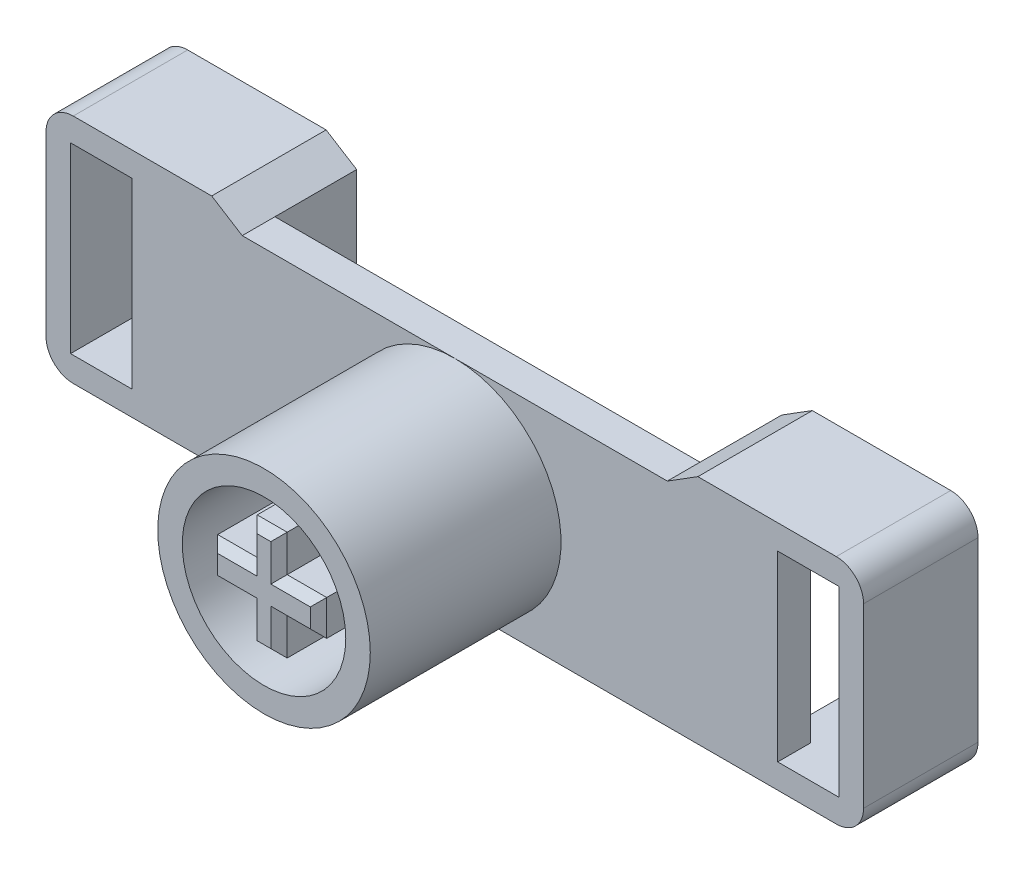
from build123d import *

# Parameters (mm, degrees)
SKETCH1_R               = 3.9
SKETCH1_R_2             = 3
SKETCH1_W               = 1.45
SKETCH1_H               = 1.3
SKETCH1_W_2             = 1.1
SKETCH1_H_2             = 1.35
BOSS_EXTRUDE1_DEPTH     = 7
SKETCH2_R               = 3
BOSS_EXTRUDE2_DEPTH     = 3
SKETCH4_W               = 30
SKETCH4_H               = 7.8
BOSS_EXTRUDE3_DEPTH     = 4.2
SKETCH3_W               = 1.45
SKETCH3_H               = 1.35
CUT_EXTRUDE3_DEPTH      = 18.180221186
CUT_EXTRUDE3_DEPTH_BACK = 18.180221186
SKETCH5_W               = 15.6
SKETCH5_H               = 7.8
CUT_EXTRUDE4_DEPTH      = 3
SKETCH6_W               = 2.25
SKETCH6_H               = 6.7
CUT_EXTRUDE5_DEPTH      = 3
CUT_EXTRUDE6_DEPTH      = 3
SKETCH8_W               = 2.25
SKETCH8_H               = 7.6
CUT_EXTRUDE7_DEPTH      = 0.4
FILLET1_R               = 1
CHAMFER1_SIZE           = 0.3


with BuildPart() as part:
    # Sketch1 → Boss-Extrude1 (new body)
    with BuildSketch(Plane.XY):
        Circle(SKETCH1_R)
        Circle(SKETCH1_R_2, mode=Mode.SUBTRACT)
        with Locations((-1.275, 0)):
            Rectangle(SKETCH1_W, SKETCH1_H)
        with Locations((0, -1.325)):
            Rectangle(SKETCH1_W_2, SKETCH1_H_2)
        Rectangle(SKETCH1_W_2, SKETCH1_H)
        with Locations((1.275, 0)):
            Rectangle(SKETCH1_W, SKETCH1_H)
        with Locations((0, 1.325)):
            Rectangle(SKETCH1_W_2, SKETCH1_H_2)
    extrude(amount=BOSS_EXTRUDE1_DEPTH)

    # Sketch2 → Boss-Extrude2 (add)
    with BuildSketch(Plane.XY):
        Circle(SKETCH2_R)
    extrude(amount=BOSS_EXTRUDE2_DEPTH)

    # Sketch4 → Boss-Extrude3 (add)
    with BuildSketch(Plane.XY):
        Polygon((-15, 4.6), (-15, 3.9), (-7.8, 3.9), (-8.92023417, 4.6), align=None)
        Rectangle(SKETCH4_W, SKETCH4_H)
        Polygon((8.92023417, 4.6), (7.8, 3.9), (15, 3.9), (15, 4.6), align=None)
    extrude(amount=-BOSS_EXTRUDE3_DEPTH)

    # Sketch3 → Cut-Extrude3 (cut, two sides)
    with BuildSketch(Plane.XY) as cut_extrude3_sk:
        with Locations((-1.275, 1.325)):
            Rectangle(SKETCH3_W, SKETCH3_H)
        with Locations((1.275, -1.325)):
            Rectangle(SKETCH3_W, SKETCH3_H)
    extrude(amount=CUT_EXTRUDE3_DEPTH, mode=Mode.SUBTRACT)
    extrude(cut_extrude3_sk.sketch, amount=-CUT_EXTRUDE3_DEPTH_BACK, mode=Mode.SUBTRACT)

    # Sketch5 → Cut-Extrude4 (cut)
    with BuildSketch(Plane(origin=(0, 0, -4.2), x_dir=(-1, 0, 0), z_dir=(0, 0, -1))):
        Rectangle(SKETCH5_W, SKETCH5_H)
    extrude(amount=-CUT_EXTRUDE4_DEPTH, mode=Mode.SUBTRACT)

    # Sketch6 → Cut-Extrude5 (cut)
    with BuildSketch(Plane.XY):
        with Locations((12.975, 0.35)):
            Rectangle(SKETCH6_W, SKETCH6_H)
        with Locations((-12.975, 0.35)):
            Rectangle(SKETCH6_W, SKETCH6_H)
    extrude(amount=-CUT_EXTRUDE5_DEPTH, mode=Mode.SUBTRACT)

    # Sketch7 → Cut-Extrude6 (cut)
    with BuildSketch(Plane(origin=(0, 0, -4.2), x_dir=(-1, 0, 0), z_dir=(0, 0, -1))):
        Polygon((12.06, -3), (10.95, -3), (10.95, -3.9), (8.7, -3.9), (8.7, 3.7), (14.1, 3.7), (14.1, 1.7), (12.06, 1.7), align=None)
        Polygon((-8.7, 3.7), (-14.1, 3.7), (-14.1, 1.7), (-12.06, 1.7), (-12.06, -3), (-10.95, -3), (-10.95, -3.9), (-8.7, -3.9), align=None)
    extrude(amount=-CUT_EXTRUDE6_DEPTH, mode=Mode.SUBTRACT)

    # Sketch8 → Cut-Extrude7 (cut)
    with BuildSketch(Plane(origin=(0, 0, -1.2), x_dir=(-1, 0, 0), z_dir=(0, 0, -1))):
        with Locations((-9.825, -0.1)):
            Rectangle(SKETCH8_W, SKETCH8_H)
        with Locations((9.825, -0.1)):
            Rectangle(SKETCH8_W, SKETCH8_H)
    extrude(amount=-CUT_EXTRUDE7_DEPTH, mode=Mode.SUBTRACT)

    # Fillet1
    fillet1_edges = [part.edges().sort_by_distance(p)[0] for p in [
        (-15, 4.6, -2.1),
        (15, 4.6, -2.1),
        (15, -3.9, -2.1),
        (-15, -3.9, -2.1),
    ]]
    fillet(fillet1_edges, radius=FILLET1_R)

    # Chamfer1
    chamfer1_edges = [part.edges().sort_by_distance(p)[0] for p in [
        (-2, 0, 7),
        (-1.275, -0.65, 7),
        (-0.55, -1.325, 7),
        (0, -2, 7),
        (0.55, -1.325, 7),
        (1.275, -0.65, 7),
        (-0.55, 1.325, 7),
        (2, 0, 7),
        (1.275, 0.65, 7),
        (0.55, 1.325, 7),
        (0, 2, 7),
        (-1.275, 0.65, 7),
    ]]
    chamfer(chamfer1_edges, length=CHAMFER1_SIZE)


solid = part.part
